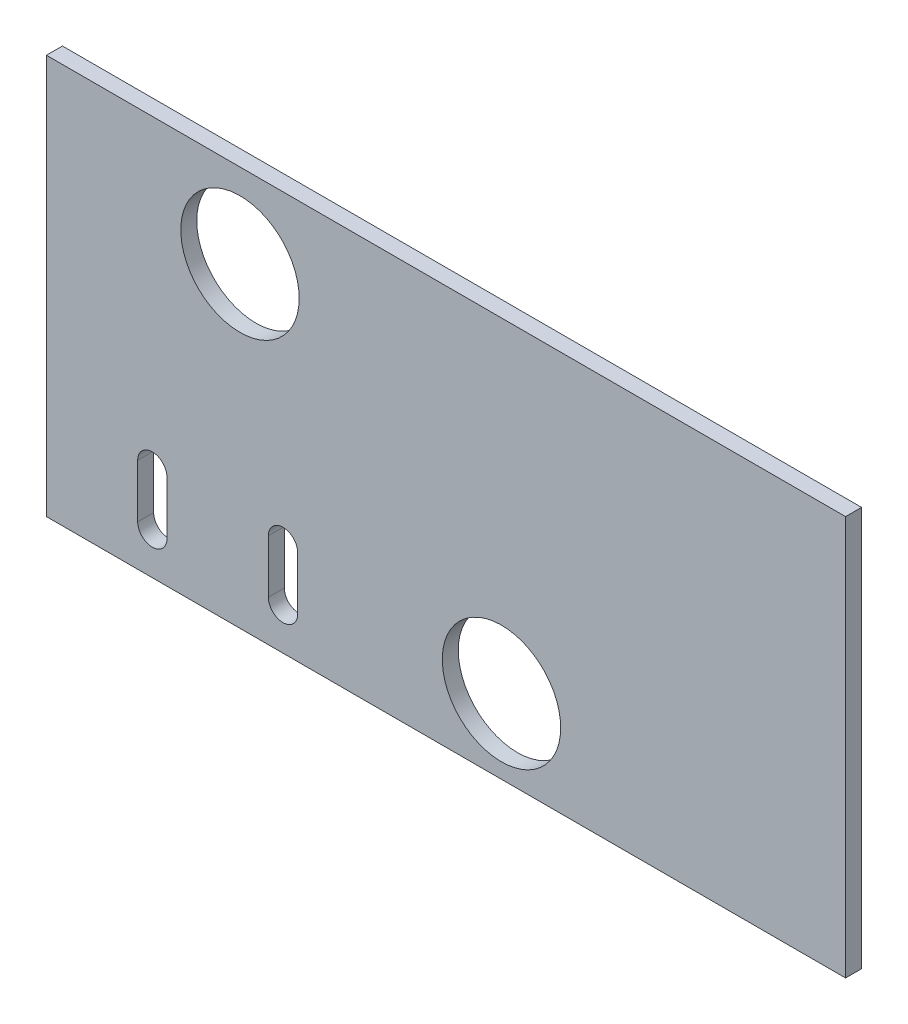
from build123d import *

# Parameters (mm, degrees)
SKETCH1_W           = 150
SKETCH1_H           = 75
BOSS_EXTRUDE1_DEPTH = 3
SKETCH2_R           = 11.11
CUT_EXTRUDE1_DEPTH  = 10


with BuildPart() as part:
    # Sketch1 → Boss-Extrude1 (new body)
    with BuildSketch(Plane.XY):
        with Locations((75, 37.5)):
            Rectangle(SKETCH1_W, SKETCH1_H)
    extrude(amount=BOSS_EXTRUDE1_DEPTH)

    # Sketch2 → Cut-Extrude1 (cut)
    with BuildSketch(Plane.XY.offset(3)):
        with Locations((36.327910431, 59.217033853)):
            Circle(SKETCH2_R)
        with Locations((85.413576885, 13.949141457)):
            Circle(SKETCH2_R)
        with BuildLine():
            Line((17.12526901, 7.718435361), (17.12526901, 17.718435361))
            ThreePointArc((17.12526901, 17.718435361), (19.87526901, 20.468435361), (22.62526901, 17.718435361))
            Line((22.62526901, 17.718435361), (22.62526901, 7.718435361))
            ThreePointArc((22.62526901, 7.718435361), (19.87526901, 4.968435361), (17.12526901, 7.718435361))
        make_face()
        with BuildLine():
            Line((41.656612513, 7.718435361), (41.656612513, 17.718435361))
            ThreePointArc((41.656612513, 17.718435361), (44.406612513, 20.468435361), (47.156612513, 17.718435361))
            Line((47.156612513, 17.718435361), (47.156612513, 7.718435361))
            ThreePointArc((47.156612513, 7.718435361), (44.406612513, 4.968435361), (41.656612513, 7.718435361))
        make_face()
    extrude(amount=-CUT_EXTRUDE1_DEPTH, mode=Mode.SUBTRACT)


solid = part.part
